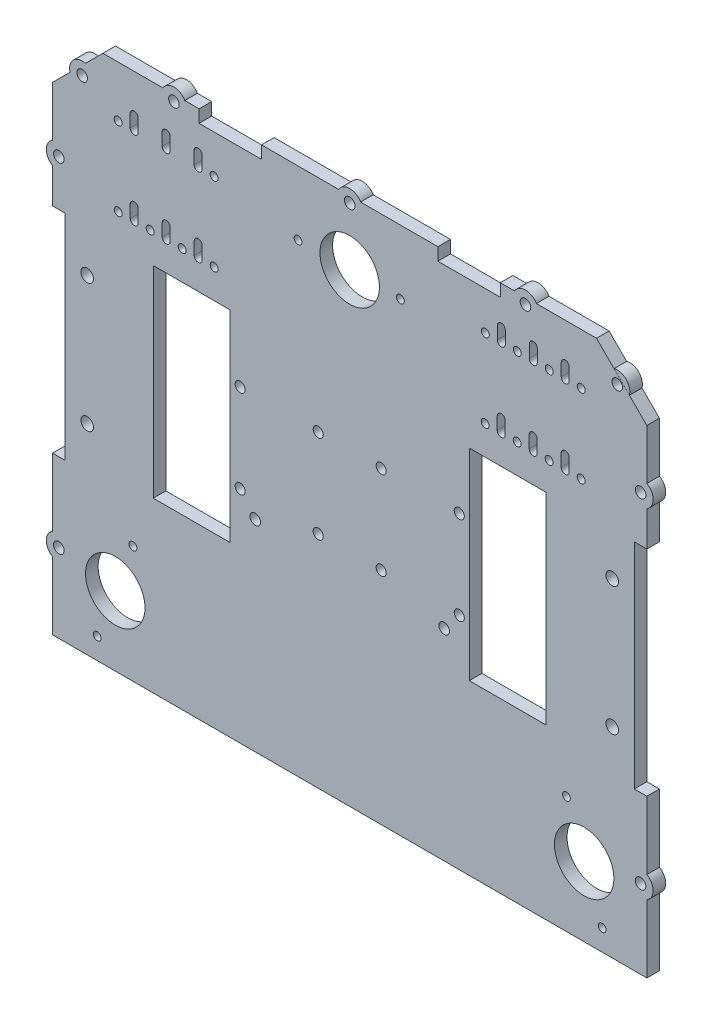
from build123d import *

# Parameters (mm, degrees)
SKETCH1_W               = 30.5
SKETCH1_H               = 80
BOSS_EXTRUDE1_DEPTH     = 5
SKETCH2_R               = 2
CUT_EXTRUDE1_DEPTH      = 6
SKETCH3_R               = 11.807611308
SKETCH3_R_2             = 1.55
SKETCH3_R_3             = 1.5875
SKETCH3_R_4             = 2.5
CUT_EXTRUDE2_DEPTH      = 6
SKETCH4_W               = 5
SKETCH4_H               = 85
CUT_EXTRUDE3_DEPTH      = 6
SKETCH7_R               = 2.1
SKETCH7_W               = 24.8
SKETCH7_H               = 5
CUT_EXTRUDE5_DEPTH      = 6
BOSS_EXTRUDE3_DEPTH     = 5
SKETCH9_R               = 2.1
CUT_EXTRUDE6_DEPTH      = 6
SKETCH10_R              = 2.1
CUT_EXTRUDE7_DEPTH      = 5
BOSS_EXTRUDE4_DEPTH     = 5
BOSS_EXTRUDE5_DEPTH     = 5
ESQUISSE1_W             = 310.321227288
ESQUISSE1_H             = 38.192755042
ENL_V_MAT_EXTRU_1_DEPTH = 10
BOSS_EXTRU_1_DEPTH      = 5


with BuildPart() as part:
    # Sketch1 → Boss-Extrude1 (new body)
    with BuildSketch(Plane.XY):
        with BuildLine():
            Line((64.226162893, -107), (118, -107))
            Line((118, -107), (118, 83))
            Line((118, 83), (98, 103))
            Line((98, 103), (-98, 103))
            Line((-98, 103), (-118, 83))
            Line((-118, 83), (-118, -107))
            Line((-118, -107), (-64.226162893, -107))
            ThreePointArc((-64.226162893, -107), (0, -32), (64.226162893, -107))
        make_face()
        with Locations((62.75, 0)):
            Rectangle(SKETCH1_W, SKETCH1_H, mode=Mode.SUBTRACT)
        with Locations((-62.75, 0)):
            Rectangle(SKETCH1_W, SKETCH1_H, mode=Mode.SUBTRACT)
    extrude(amount=BOSS_EXTRUDE1_DEPTH)

    # Sketch2 → Cut-Extrude1 (cut, through all)
    with BuildSketch(Plane.XY.offset(5)):
        with Locations((43.5, 15.5)):
            Circle(SKETCH2_R)
        with Locations((43.5, -19.5)):
            Circle(SKETCH2_R)
        with Locations((12.5, -19.5)):
            Circle(SKETCH2_R)
        with Locations((12.5, 15.5)):
            Circle(SKETCH2_R)
        with Locations((-12.5, 15.5)):
            Circle(SKETCH2_R)
        with Locations((-12.5, -19.5)):
            Circle(SKETCH2_R)
        with Locations((-43.5, -19.5)):
            Circle(SKETCH2_R)
        with Locations((-43.5, 15.5)):
            Circle(SKETCH2_R)
    extrude(amount=-CUT_EXTRUDE1_DEPTH, mode=Mode.SUBTRACT)

    # Sketch3 → Cut-Extrude2 (cut, through all)
    with BuildSketch(Plane.XY.offset(5)):
        with Locations((0, 77.5)):
            Circle(SKETCH3_R)
        with Locations((20.138291871, 77.5)):
            Circle(SKETCH3_R_2)
        with Locations((-20.503494055, 77.5)):
            Circle(SKETCH3_R_2)
        with BuildLine():
            Line((-71.2975, 87.747), (-71.3, 82.747))
            ThreePointArc((-71.3, 82.747), (-72.8875, 81.1595), (-74.475, 82.747))
            Line((-74.475, 82.747), (-74.4775, 87.747))
            ThreePointArc((-74.4775, 87.747), (-72.8875, 89.337), (-71.2975, 87.747))
        make_face()
        with BuildLine():
            Line((-58.5975, 87.747), (-58.6, 82.747))
            ThreePointArc((-58.6, 82.747), (-60.1875, 81.1595), (-61.775, 82.747))
            Line((-61.775, 82.747), (-61.7775, 87.747))
            ThreePointArc((-61.7775, 87.747), (-60.1875, 89.337), (-58.5975, 87.747))
        make_face()
        with BuildLine():
            ThreePointArc((-87.175, 87.747), (-85.5875, 89.3345), (-84, 87.747))
            Line((-84, 87.747), (-84, 82.747))
            ThreePointArc((-84, 82.747), (-85.5875, 81.1595), (-87.175, 82.747))
            Line((-87.175, 82.747), (-87.175, 87.747))
        make_face()
        with Locations((-91.9375, 82.747)):
            Circle(SKETCH3_R_3)
        with Locations((-91.910884632, 51.582790514)):
            Circle(SKETCH3_R_3)
        with BuildLine():
            Line((-87.148384632, 56.582790514), (-87.148384632, 51.582790514))
            ThreePointArc((-87.148384632, 51.582790514), (-85.560884632, 49.995290514), (-83.973384632, 51.582790514))
            Line((-83.973384632, 51.582790514), (-83.973384632, 56.582790514))
            ThreePointArc((-83.973384632, 56.582790514), (-85.560884632, 58.170290514), (-87.148384632, 56.582790514))
        make_face()
        with BuildLine():
            Line((-74.450884632, 56.582790514), (-74.448384632, 51.582790514))
            ThreePointArc((-74.448384632, 51.582790514), (-72.860884632, 49.995290514), (-71.273384632, 51.582790514))
            Line((-71.273384632, 51.582790514), (-71.270884632, 56.582790514))
            ThreePointArc((-71.270884632, 56.582790514), (-72.860884632, 58.172790514), (-74.450884632, 56.582790514))
        make_face()
        with Locations((-79.210884632, 51.582790514)):
            Circle(SKETCH3_R_3)
        with BuildLine():
            Line((-61.750884632, 56.582790514), (-61.748384632, 51.582790514))
            ThreePointArc((-61.748384632, 51.582790514), (-60.160884632, 49.995290514), (-58.573384632, 51.582790514))
            Line((-58.573384632, 51.582790514), (-58.570884632, 56.582790514))
            ThreePointArc((-58.570884632, 56.582790514), (-60.160884632, 58.172790514), (-61.750884632, 56.582790514))
        make_face()
        with Locations((-66.510884632, 51.582790514)):
            Circle(SKETCH3_R_3)
        with Locations((-53.810884632, 51.582790514)):
            Circle(SKETCH3_R_3)
        with BuildLine():
            ThreePointArc((87.175, 82.747), (85.5875, 81.1595), (84, 82.747))
            Line((84, 82.747), (84, 87.747))
            ThreePointArc((84, 87.747), (85.5875, 89.3345), (87.175, 87.747))
            Line((87.175, 87.747), (87.175, 82.747))
        make_face()
        with Locations((79.2375, 82.747)):
            Circle(SKETCH3_R_3)
        with BuildLine():
            ThreePointArc((74.475, 82.747), (72.8875, 81.1595), (71.3, 82.747))
            Line((71.3, 82.747), (71.2975, 87.747))
            ThreePointArc((71.2975, 87.747), (72.8875, 89.337), (74.4775, 87.747))
            Line((74.4775, 87.747), (74.475, 82.747))
        make_face()
        with BuildLine():
            ThreePointArc((58.5975, 87.747), (60.1875, 89.337), (61.7775, 87.747))
            Line((61.7775, 87.747), (61.775, 82.747))
            ThreePointArc((61.775, 82.747), (60.1875, 81.1595), (58.6, 82.747))
            Line((58.6, 82.747), (58.5975, 87.747))
        make_face()
        with Locations((53.8375, 82.747)):
            Circle(SKETCH3_R_3)
        with Locations((66.5375, 82.747)):
            Circle(SKETCH3_R_3)
        with Locations((91.9375, 82.747)):
            Circle(SKETCH3_R_3)
        with BuildLine():
            Line((87.148384632, 56.582790514), (87.148384632, 51.582790514))
            ThreePointArc((87.148384632, 51.582790514), (85.560884632, 49.995290514), (83.973384632, 51.582790514))
            Line((83.973384632, 51.582790514), (83.973384632, 56.582790514))
            ThreePointArc((83.973384632, 56.582790514), (85.560884632, 58.170290514), (87.148384632, 56.582790514))
        make_face()
        with Locations((91.910884632, 51.582790514)):
            Circle(SKETCH3_R_3)
        with Locations((79.210884632, 51.582790514)):
            Circle(SKETCH3_R_3)
        with BuildLine():
            ThreePointArc((71.270884632, 56.582790514), (72.860884632, 58.172790514), (74.450884632, 56.582790514))
            Line((74.450884632, 56.582790514), (74.448384632, 51.582790514))
            ThreePointArc((74.448384632, 51.582790514), (72.860884632, 49.995290514), (71.273384632, 51.582790514))
            Line((71.273384632, 51.582790514), (71.270884632, 56.582790514))
        make_face()
        with Locations((66.510884632, 51.582790514)):
            Circle(SKETCH3_R_3)
        with BuildLine():
            ThreePointArc((58.570884632, 56.582790514), (60.160884632, 58.172790514), (61.750884632, 56.582790514))
            Line((61.750884632, 56.582790514), (61.748384632, 51.582790514))
            ThreePointArc((61.748384632, 51.582790514), (60.160884632, 49.995290514), (58.573384632, 51.582790514))
            Line((58.573384632, 51.582790514), (58.570884632, 56.582790514))
        make_face()
        with Locations((53.810884632, 51.582790514)):
            Circle(SKETCH3_R_3)
        with Locations((104.25, 23.5)):
            Circle(SKETCH3_R_4)
        with Locations((104.25, -27.5)):
            Circle(SKETCH3_R_4)
        with Locations((93.092103794, -79.3816003)):
            Circle(SKETCH3_R)
        with Locations((86.056787146, -60.512177438)):
            Circle(SKETCH3_R_2)
        with Locations((100.255003904, -98.593214768)):
            Circle(SKETCH3_R_2)
        with Locations((-104.25, 23.5)):
            Circle(SKETCH3_R_4)
        with Locations((-104.25, -27.5)):
            Circle(SKETCH3_R_4)
        with Locations((-93.092103794, -79.3816003)):
            Circle(SKETCH3_R)
        with Locations((-100.255003904, -98.593214768)):
            Circle(SKETCH3_R_2)
        with Locations((-86.056787146, -60.512177438)):
            Circle(SKETCH3_R_2)
        with Locations((-53.8375, 82.747)):
            Circle(SKETCH3_R_3)
    extrude(amount=-CUT_EXTRUDE2_DEPTH, mode=Mode.SUBTRACT)

    # Sketch4 → Cut-Extrude3 (cut, through all)
    with BuildSketch(Plane.XY.offset(5)):
        with Locations((-115.5, -2)):
            Rectangle(SKETCH4_W, SKETCH4_H)
        with Locations((115.5, -2)):
            Rectangle(SKETCH4_W, SKETCH4_H)
    extrude(amount=-CUT_EXTRUDE3_DEPTH, mode=Mode.SUBTRACT)

    # Sketch7 → Cut-Extrude5 (cut, through all)
    with BuildSketch(Plane(origin=(0, 0, 0), x_dir=(-1, 0, 0), z_dir=(0, 0, -1))):
        with Locations((0, 100.5)):
            Circle(SKETCH7_R)
        with Locations((69.8, 100.5)):
            Circle(SKETCH7_R)
        with Locations((-69.8, 100.5)):
            Circle(SKETCH7_R)
        with Locations((-47.4, 100.5)):
            Rectangle(SKETCH7_W, SKETCH7_H)
        with Locations((47.4, 100.5)):
            Rectangle(SKETCH7_W, SKETCH7_H)
    extrude(amount=-CUT_EXTRUDE5_DEPTH, mode=Mode.SUBTRACT)

    # Sketch8 → Boss-Extrude3 (add)
    with BuildSketch(Plane(origin=(0, 0, 0), x_dir=(-1, 0, 0), z_dir=(0, 0, -1))):
        with BuildLine():
            Line((-74.130127019, 103), (-65.469872981, 103))
            ThreePointArc((-65.469872981, 103), (-69.8, 105.5), (-74.130127019, 103))
        make_face()
        with BuildLine():
            Line((-4.330127019, 103), (4.330127019, 103))
            ThreePointArc((4.330127019, 103), (0, 105.5), (-4.330127019, 103))
        make_face()
        with BuildLine():
            Line((65.469872981, 103), (74.130127019, 103))
            ThreePointArc((74.130127019, 103), (69.8, 105.5), (65.469872981, 103))
        make_face()
    extrude(amount=-BOSS_EXTRUDE3_DEPTH)

    # Sketch9 → Cut-Extrude6 (cut, through all)
    with BuildSketch(Plane.XY.offset(5)):
        with Locations((37.5, -27)):
            Circle(SKETCH9_R)
        with Locations((-37.5, -27)):
            Circle(SKETCH9_R)
    extrude(amount=-CUT_EXTRUDE6_DEPTH, mode=Mode.SUBTRACT)

    # Sketch10 → Cut-Extrude7 (cut)
    with BuildSketch(Plane(origin=(0, 0, 0), x_dir=(-1, 0, 0), z_dir=(0, 0, -1))):
        with Locations((-115.5, -75.75)):
            Circle(SKETCH10_R)
        with Locations((115.5, -75.75)):
            Circle(SKETCH10_R)
        with Locations((-115.5, 58.75)):
            Circle(SKETCH10_R)
        with Locations((115.5, 58.75)):
            Circle(SKETCH10_R)
        with Locations((-106.232988104, 91.23147799)):
            Circle(SKETCH10_R)
        with Locations((106.232988104, 91.23147799)):
            Circle(SKETCH10_R)
    extrude(amount=-CUT_EXTRUDE7_DEPTH, mode=Mode.SUBTRACT)

    # Sketch11 → Boss-Extrude4 (add)
    with BuildSketch(Plane(origin=(0, 0, 0), x_dir=(-1, 0, 0), z_dir=(0, 0, -1))):
        with BuildLine():
            Line((-118, 54.419872981), (-118, 63.080127019))
            ThreePointArc((-118, 63.080127019), (-120.5, 58.75), (-118, 54.419872981))
        make_face()
        with BuildLine():
            Line((-118, -71.419872981), (-118, -80.080127019))
            ThreePointArc((-118, -80.080127019), (-120.5, -75.75), (-118, -71.419872981))
        make_face()
        with BuildLine():
            Line((118, -71.419872981), (118, -80.080127019))
            ThreePointArc((118, -80.080127019), (120.5, -75.75), (118, -71.419872981))
        make_face()
        with BuildLine():
            Line((118, 63.080127019), (118, 54.419872981))
            ThreePointArc((118, 54.419872981), (120.5, 58.75), (118, 63.080127019))
        make_face()
        with BuildLine():
            Line((104.938892879, 96.061107121), (111.062617235, 89.937382765))
            ThreePointArc((111.062617235, 89.937382765), (109.76852201, 94.767011896), (104.938892879, 96.061107121))
        make_face()
        with BuildLine():
            Line((-104.999243157, 96.076875126), (-111.062617235, 89.937382765))
            ThreePointArc((-111.062617235, 89.937382765), (-109.790506534, 94.74488981), (-104.999243157, 96.076875126))
        make_face()
    extrude(amount=-BOSS_EXTRUDE4_DEPTH)

    # Sketch12 → Boss-Extrude5 (add)
    with BuildSketch(Plane(origin=(0, 0, 0), x_dir=(-1, 0, 0), z_dir=(0, 0, -1))):
        with BuildLine():
            Line((-118, -107), (-131.113081447, -114))
            Line((-131.113081447, -114), (-130.96004758, -132.646136562))
            ThreePointArc((-130.96004758, -132.646136562), (-98.682553111, -119.442249894), (-64.226162893, -124.821510574))
            Line((-64.226162893, -124.821510574), (-64.226162893, -107))
            Line((-64.226162893, -107), (-118, -107))
        make_face()
        with BuildLine():
            Line((118, -107), (64.226162893, -107))
            Line((64.226162893, -107), (64.226162893, -124.821510574))
            ThreePointArc((64.226162893, -124.821510574), (98.682553111, -119.442249894), (130.96004758, -132.646136562))
            Line((130.96004758, -132.646136562), (131.113081447, -114))
            Line((131.113081447, -114), (118, -107))
        make_face()
    extrude(amount=-BOSS_EXTRUDE5_DEPTH)

    # Esquisse1 → Enlèv. mat.-Extru.1 (cut)
    with BuildSketch(Plane.XY.offset(5)):
        with Locations((2.008551633, -126.096377521)):
            Rectangle(ESQUISSE1_W, ESQUISSE1_H)
    extrude(amount=-ENL_V_MAT_EXTRU_1_DEPTH, mode=Mode.SUBTRACT)

    # Esquisse2 → Boss.-Extru.1 (add)
    with BuildSketch(Plane.XY.offset(5)):
        with BuildLine():
            Line((-64.226162893, -107), (64.226162893, -107))
            ThreePointArc((64.226162893, -107), (0, -32), (-64.226162893, -107))
        make_face()
    extrude(amount=-BOSS_EXTRU_1_DEPTH)


solid = part.part
